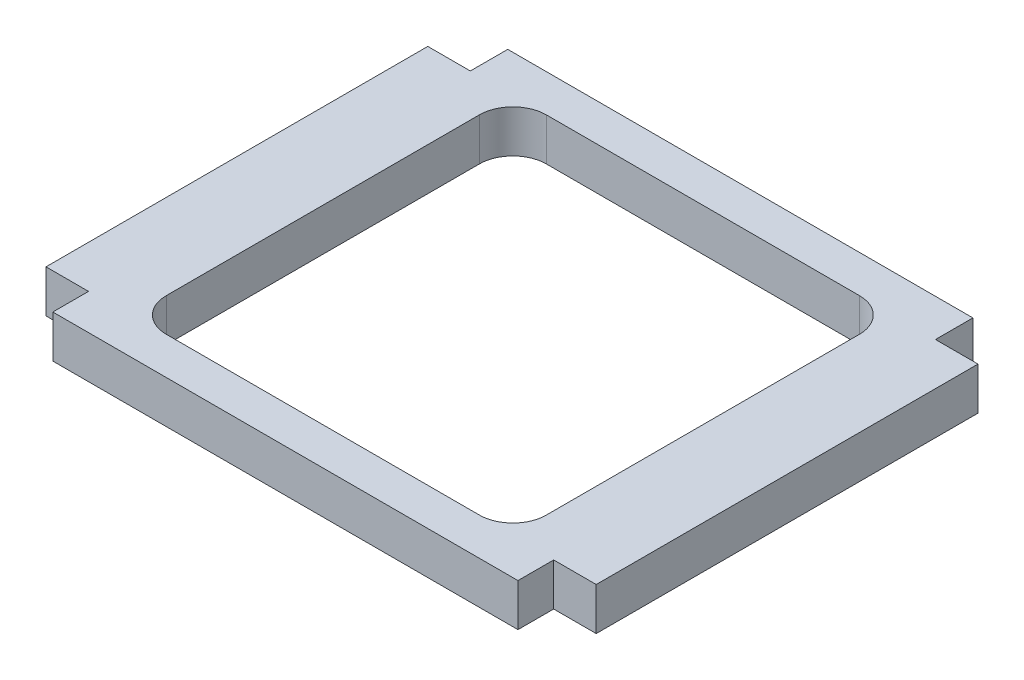
from build123d import *

# Parameters (mm, degrees)
BOSS_EXTRUDE1_DEPTH = 6.35


with BuildPart() as part:
    # Sketch1 → Boss-Extrude1 (new body)
    with BuildSketch(Plane(origin=(0, 0, 0), x_dir=(1, 0, 0), z_dir=(0, 1, 0))):
        Polygon((-41.0718, -28.6282), (-41.0718, 28.3718), (-34.7218, 28.3718), (-34.7218, 33.9598), (34.7218, 33.9598), (34.7218, 28.3718), (41.0718, 28.3718), (41.0718, -28.6282), (34.7218, -28.6282), (34.7218, -33.9598), (-34.7218, -33.9598), (-34.7218, -28.6282), align=None)
        with BuildLine():
            Line((-23.3718, -28.3718), (23.3718, -28.3718))
            ThreePointArc((23.3718, -28.3718), (26.907333906, -26.907333906), (28.3718, -23.3718))
            Line((28.3718, -23.3718), (28.3718, 23.3718))
            ThreePointArc((28.3718, 23.3718), (26.907333906, 26.907333906), (23.3718, 28.3718))
            Line((23.3718, 28.3718), (-23.3718, 28.3718))
            ThreePointArc((-23.3718, 28.3718), (-26.907333906, 26.907333906), (-28.3718, 23.3718))
            Line((-28.3718, 23.3718), (-28.3718, -23.3718))
            ThreePointArc((-28.3718, -23.3718), (-26.907333906, -26.907333906), (-23.3718, -28.3718))
        make_face(mode=Mode.SUBTRACT)
    extrude(amount=BOSS_EXTRUDE1_DEPTH)


solid = part.part
